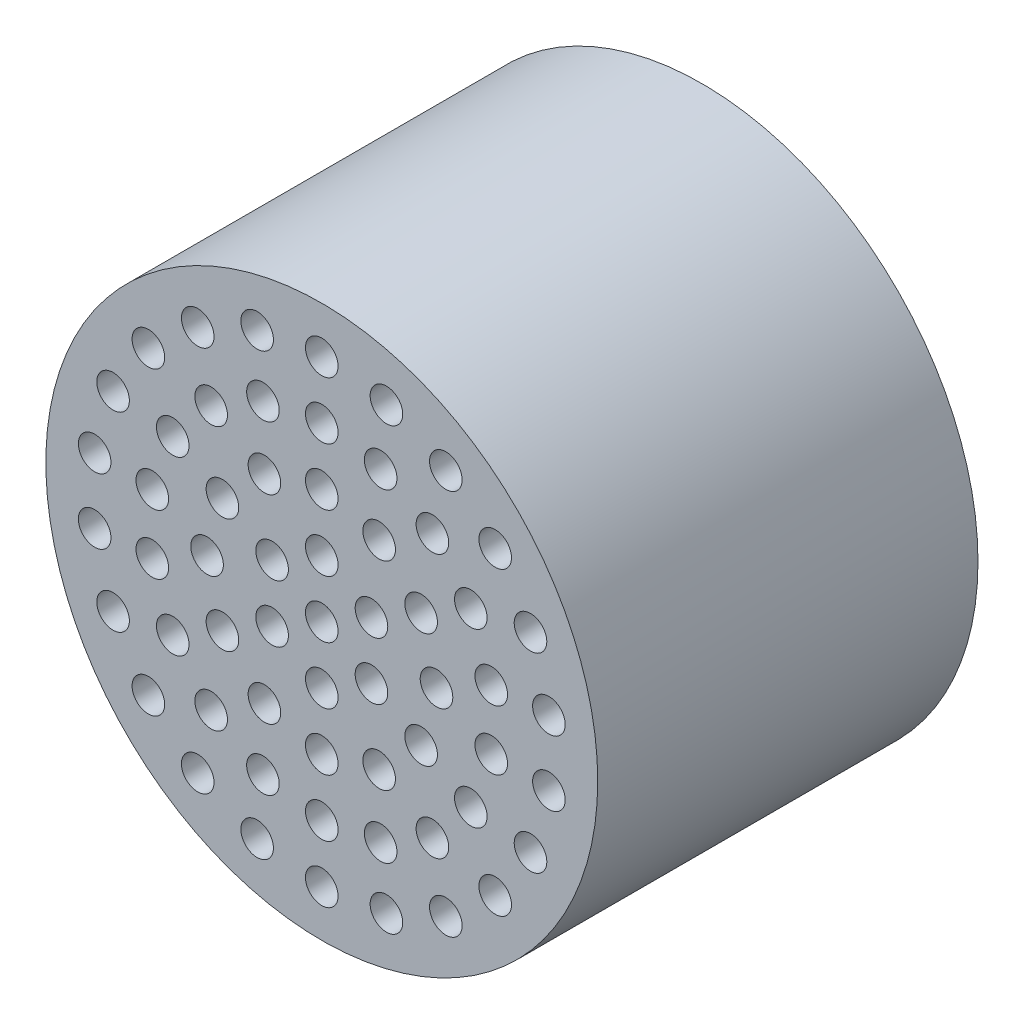
from build123d import *

# Parameters (mm, degrees)
ESQUISSE1_R             = 25.4
BOSS_EXTRU_1_DEPTH      = 25
ESQUISSE6_R             = 1.55
ENL_V_MAT_EXTRU_4_DEPTH = 11
ESQUISSE8_R             = 25.4
BOSS_EXTRU_3_DEPTH      = 10
ESQUISSE9_R             = 1.5
ENL_V_MAT_EXTRU_5_DEPTH = 10


with BuildPart() as part:
    # Esquisse1 → Boss.-Extru.1 (new body)
    with BuildSketch(Plane.XY):
        with Locations((16.625210007, 7.108710486)):
            Circle(ESQUISSE1_R)
    extrude(amount=BOSS_EXTRU_1_DEPTH)

    # Esquisse6 → Enlèv. mat.-Extru.4 (cut)
    with BuildSketch(Plane(origin=(0, 0, 0), x_dir=(-1, 0, 0), z_dir=(0, 0, -1))):
        with Locations((-39.525210007, 7.108710486)):
            Circle(ESQUISSE6_R)
        with Locations((6.274789993, 7.108710486)):
            Circle(ESQUISSE6_R)
    extrude(amount=-ENL_V_MAT_EXTRU_4_DEPTH, mode=Mode.SUBTRACT)

    # Esquisse8 → Boss.-Extru.3 (add)
    with BuildSketch(Plane.XY.offset(25)):
        with Locations((16.625210007, 7.108710486)):
            Circle(ESQUISSE8_R)
    extrude(amount=BOSS_EXTRU_3_DEPTH)

    # Esquisse9 → Enlèv. mat.-Extru.5 (cut)
    with BuildSketch(Plane.XY.offset(35)):
        with Locations((16.625210007, 7.108710486)):
            Circle(ESQUISSE9_R)
        with Locations((16.625210007, 12.388710486)):
            Circle(ESQUISSE9_R)
        with Locations((21.197824139, 9.748710486)):
            Circle(ESQUISSE9_R)
        with Locations((21.197824139, 4.468710486)):
            Circle(ESQUISSE9_R)
        with Locations((16.625210007, 1.828710486)):
            Circle(ESQUISSE9_R)
        with Locations((12.052595875, 4.468710486)):
            Circle(ESQUISSE9_R)
        with Locations((12.052595875, 9.748710486)):
            Circle(ESQUISSE9_R)
        with Locations((16.625210007, 17.668710486)):
            Circle(ESQUISSE9_R)
        with Locations((21.905210007, 16.25393875)):
            Circle(ESQUISSE9_R)
        with Locations((25.770438271, 12.388710486)):
            Circle(ESQUISSE9_R)
        with Locations((27.185210007, 7.108710486)):
            Circle(ESQUISSE9_R)
        with Locations((25.770438271, 1.828710486)):
            Circle(ESQUISSE9_R)
        with Locations((21.905210007, -2.036517778)):
            Circle(ESQUISSE9_R)
        with Locations((16.625210007, -3.451289514)):
            Circle(ESQUISSE9_R)
        with Locations((11.345210007, -2.036517778)):
            Circle(ESQUISSE9_R)
        with Locations((7.479981743, 1.828710486)):
            Circle(ESQUISSE9_R)
        with Locations((6.065210007, 7.108710486)):
            Circle(ESQUISSE9_R)
        with Locations((7.479981743, 12.388710486)):
            Circle(ESQUISSE9_R)
        with Locations((11.345210007, 16.25393875)):
            Circle(ESQUISSE9_R)
        with Locations((16.625210007, 22.948710486)):
            Circle(ESQUISSE9_R)
        with Locations((22.042809078, 21.993441599)):
            Circle(ESQUISSE9_R)
        with Locations((26.806965745, 19.242854465)):
            Circle(ESQUISSE9_R)
        with Locations((30.343052403, 15.028710486)):
            Circle(ESQUISSE9_R)
        with Locations((32.224564815, 9.85929762)):
            Circle(ESQUISSE9_R)
        with Locations((32.224564815, 4.358123352)):
            Circle(ESQUISSE9_R)
        with Locations((30.343052403, -0.811289514)):
            Circle(ESQUISSE9_R)
        with Locations((26.806965745, -5.025433493)):
            Circle(ESQUISSE9_R)
        with Locations((22.042809078, -7.776020627)):
            Circle(ESQUISSE9_R)
        with Locations((16.625210007, -8.731289514)):
            Circle(ESQUISSE9_R)
        with Locations((11.207610937, -7.776020627)):
            Circle(ESQUISSE9_R)
        with Locations((6.44345427, -5.025433493)):
            Circle(ESQUISSE9_R)
        with Locations((2.907367612, -0.811289514)):
            Circle(ESQUISSE9_R)
        with Locations((1.0258552, 4.358123352)):
            Circle(ESQUISSE9_R)
        with Locations((1.0258552, 9.85929762)):
            Circle(ESQUISSE9_R)
        with Locations((2.907367612, 15.028710486)):
            Circle(ESQUISSE9_R)
        with Locations((6.44345427, 19.242854465)):
            Circle(ESQUISSE9_R)
        with Locations((11.207610937, 21.993441599)):
            Circle(ESQUISSE9_R)
        with Locations((16.625210007, 28.228710486)):
            Circle(ESQUISSE9_R)
        with Locations((22.575401608, 27.373202089)):
            Circle(ESQUISSE9_R)
        with Locations((28.043544072, 24.875985099)):
            Circle(ESQUISSE9_R)
        with Locations((32.586641018, 20.939369187)):
            Circle(ESQUISSE9_R)
        with Locations((35.836637749, 15.882275561)):
            Circle(ESQUISSE9_R)
        with Locations((37.53023886, 10.11439987)):
            Circle(ESQUISSE9_R)
        with Locations((37.53023886, 4.103021102)):
            Circle(ESQUISSE9_R)
        with Locations((35.836637749, -1.664854589)):
            Circle(ESQUISSE9_R)
        with Locations((32.586641018, -6.721948215)):
            Circle(ESQUISSE9_R)
        with Locations((28.043544072, -10.658564127)):
            Circle(ESQUISSE9_R)
        with Locations((22.575401608, -13.155781117)):
            Circle(ESQUISSE9_R)
        with Locations((16.625210007, -14.011289514)):
            Circle(ESQUISSE9_R)
        with Locations((10.675018407, -13.155781117)):
            Circle(ESQUISSE9_R)
        with Locations((5.206875943, -10.658564127)):
            Circle(ESQUISSE9_R)
        with Locations((0.663778997, -6.721948215)):
            Circle(ESQUISSE9_R)
        with Locations((-2.586217734, -1.664854589)):
            Circle(ESQUISSE9_R)
        with Locations((-4.279818845, 4.103021102)):
            Circle(ESQUISSE9_R)
        with Locations((-4.279818845, 10.11439987)):
            Circle(ESQUISSE9_R)
        with Locations((-2.586217734, 15.882275561)):
            Circle(ESQUISSE9_R)
        with Locations((0.663778997, 20.939369187)):
            Circle(ESQUISSE9_R)
        with Locations((5.206875943, 24.875985099)):
            Circle(ESQUISSE9_R)
        with Locations((10.675018407, 27.373202089)):
            Circle(ESQUISSE9_R)
    extrude(amount=-ENL_V_MAT_EXTRU_5_DEPTH, mode=Mode.SUBTRACT)

    # Esquisse12 → Enlèvement de matière-Révolution1 (revolve, cut)
    with BuildSketch(Plane(origin=(16.625210007, 0, 0), x_dir=(0, 0, -1), z_dir=(1, 0, 0))):
        Polygon((0, 7.108710486), (0, 27.108710486), (-25, 30.108710486), (-25, 7.108710486), align=None)
    revolve(axis=Axis((16.625210007, 7.108710486, 25), (0, 0, -1)), mode=Mode.SUBTRACT)


solid = part.part
